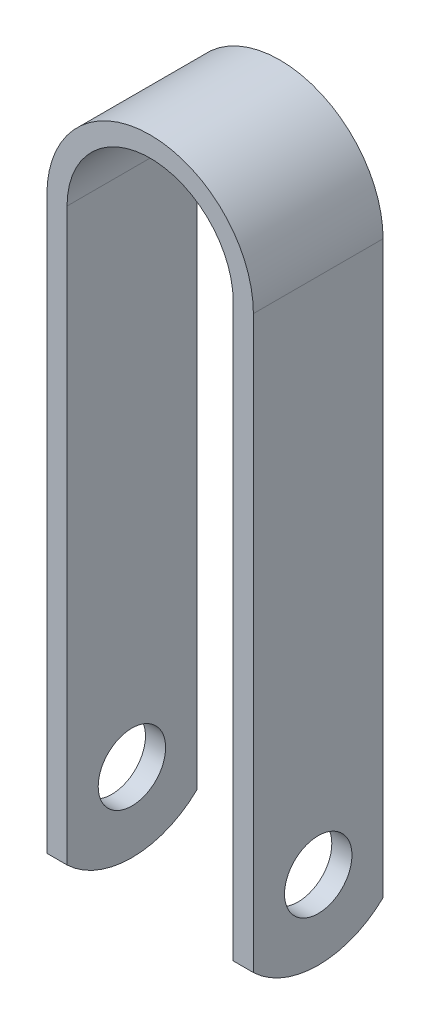
from build123d import *

# Parameters (mm, degrees)
BOSS_EXTRUDE1_DEPTH     = 9.6139
CUT_EXTRUDE1_DEPTH      = 109.617591775
CUT_EXTRUDE1_DEPTH_BACK = 109.617591775
SKETCH2_R               = 4.99745
CUT_EXTRUDE2_DEPTH      = 109.617591775
CUT_EXTRUDE2_DEPTH_BACK = 109.617591775


with BuildPart() as part:
    # Sketch1 → Boss-Extrude1 (new, symmetric)
    with BuildSketch(Plane.XY):
        with BuildLine():
            Line((0, 0), (0, 88.4682))
            ThreePointArc((0, 88.4682), (15.3035, 103.7717), (30.607, 88.4682))
            Line((30.607, 88.4682), (30.607, 0))
            Line((30.607, 0), (27.6225, 0))
            Line((27.6225, 0), (27.6225, 88.4682))
            ThreePointArc((27.6225, 88.4682), (15.3035, 100.7872), (2.9845, 88.4682))
            Line((2.9845, 88.4682), (2.9845, 0))
            Line((2.9845, 0), (0, 0))
        make_face()
    extrude(amount=BOSS_EXTRUDE1_DEPTH, both=True)

    # Sketch2 → Cut-Extrude1 (cut, two sides: drawn at the far end of the back side and taken through both)
    with BuildSketch(Plane(origin=(30.607, 0, 0), x_dir=(0, 0, -1), z_dir=(1, 0, 0)).offset(-CUT_EXTRUDE1_DEPTH_BACK)):
        with Locations((0, 11.63955)):
            Circle(SKETCH2_R)
    extrude(amount=CUT_EXTRUDE1_DEPTH + CUT_EXTRUDE1_DEPTH_BACK, mode=Mode.SUBTRACT)

    # Sketch2_3 → Cut-Extrude2 (cut, two sides: drawn at the far end of the back side and taken through both)
    with BuildSketch(Plane(origin=(30.607, 0, 0), x_dir=(0, 0, -1), z_dir=(1, 0, 0)).offset(-CUT_EXTRUDE2_DEPTH_BACK)):
        with BuildLine():
            ThreePointArc((0, 0), (-5.182448154, 1.004775894), (-9.6139, 3.8735))
            Line((-9.6139, 3.8735), (-9.6139, 0))
            Line((-9.6139, 0), (0, 0))
        make_face()
        with BuildLine():
            ThreePointArc((9.6139, 3.8735), (5.182448154, 1.004775894), (0, 0))
            Line((0, 0), (9.6139, 0))
            Line((9.6139, 0), (9.6139, 3.8735))
        make_face()
    extrude(amount=CUT_EXTRUDE2_DEPTH + CUT_EXTRUDE2_DEPTH_BACK, mode=Mode.SUBTRACT)


solid = part.part
